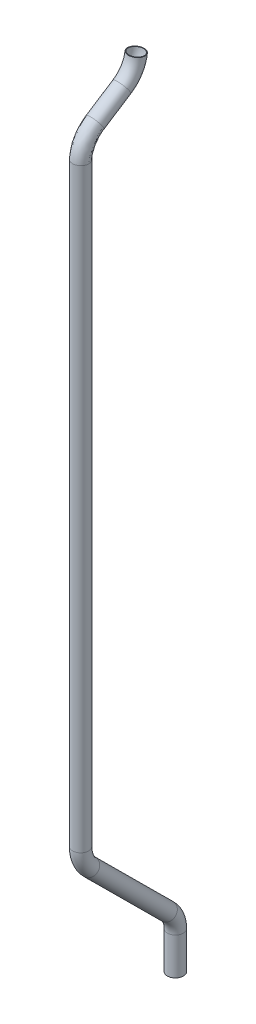
from build123d import *

# Parameters (mm, degrees)
SKETCH1_R   = 9.525
SKETCH1_R_2 = 8.763


with BuildPart() as part:
    # Sweep1: sweep along a path in Sketch4
    with BuildLine(Plane(origin=(0, 0, 0), x_dir=(0, 0, -1), z_dir=(1, 0, 0))) as sweep1_path:
        Line((0, 0), (0, 44.45))
        ThreePointArc((0, 44.45), (-2.434581157, 56.642978228), (-9.364958619, 66.966048107))
        Line((-9.364958619, 66.966048107), (-102.131076821, 159.192418597))
        ThreePointArc((-102.131076821, 159.192418597), (-110.447529775, 171.580102452), (-113.369027163, 186.211676326))
        Line((-113.369027163, 186.211676326), (-113.369027163, 897.411676326))
        ThreePointArc((-113.369027163, 897.411676326), (-108.254814534, 914.37875131), (-96.018442631, 927.197019796))
        Line((-96.018442631, 927.197019796), (-64.022648081, 947.882259246))
        ThreePointArc((-64.022648081, 947.882259246), (-52.338028271, 959.78322333), (-46.856249738, 975.534838814))
    # Sketch1 → Sweep1 (sweep)
    with BuildSketch(Plane(origin=(0, 0, 0), x_dir=(1, 0, 0), z_dir=(0, 1, 0))):
        Circle(SKETCH1_R)
        Circle(SKETCH1_R_2, mode=Mode.SUBTRACT)
    sweep(path=sweep1_path.line, transition=Transition.RIGHT)


solid = part.part
